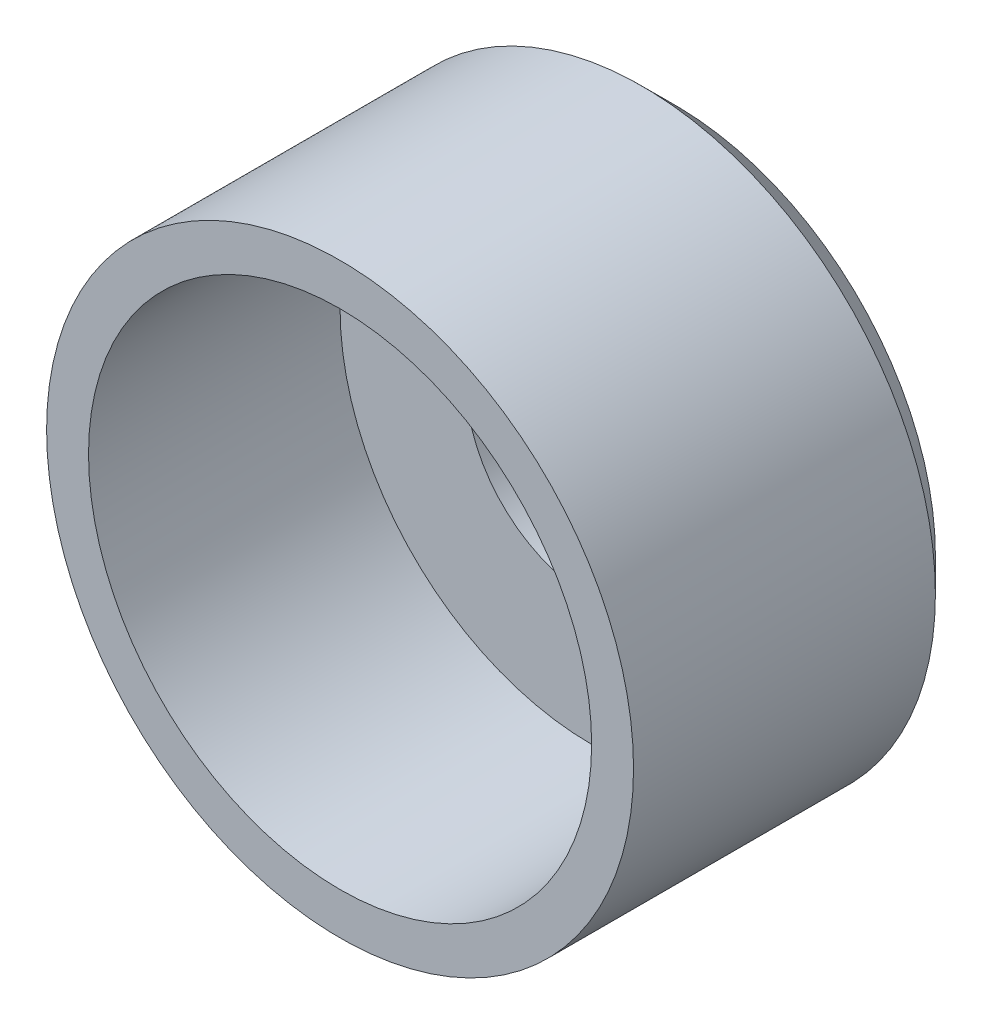
from build123d import *

# Parameters (mm, degrees)
SKETCH1_R           = 17.5
BOSS_EXTRUDE1_DEPTH = 5
SKETCH2_R           = 17.5
SKETCH2_R_2         = 15
BOSS_EXTRUDE2_DEPTH = 15
SKETCH3_R           = 7.5
CUT_EXTRUDE1_DEPTH  = 21
CHAMFER1_SIZE       = 2


with BuildPart() as part:
    # Sketch1 → Boss-Extrude1 (new body)
    with BuildSketch(Plane.XY):
        Circle(SKETCH1_R)
    extrude(amount=BOSS_EXTRUDE1_DEPTH)

    # Sketch2 → Boss-Extrude2 (add)
    with BuildSketch(Plane.XY.offset(5)):
        Circle(SKETCH2_R)
        Circle(SKETCH2_R_2, mode=Mode.SUBTRACT)
    extrude(amount=BOSS_EXTRUDE2_DEPTH)

    # Sketch3 → Cut-Extrude1 (cut, through all)
    with BuildSketch(Plane(origin=(0, 0, 0), x_dir=(-1, 0, 0), z_dir=(0, 0, -1))):
        Circle(SKETCH3_R)
    extrude(amount=-CUT_EXTRUDE1_DEPTH, mode=Mode.SUBTRACT)

    # Chamfer1
    chamfer1_edges = [part.edges().sort_by_distance(p)[0] for p in [
        (-17.5, 0, 0),
    ]]
    chamfer(chamfer1_edges, length=CHAMFER1_SIZE)


solid = part.part
